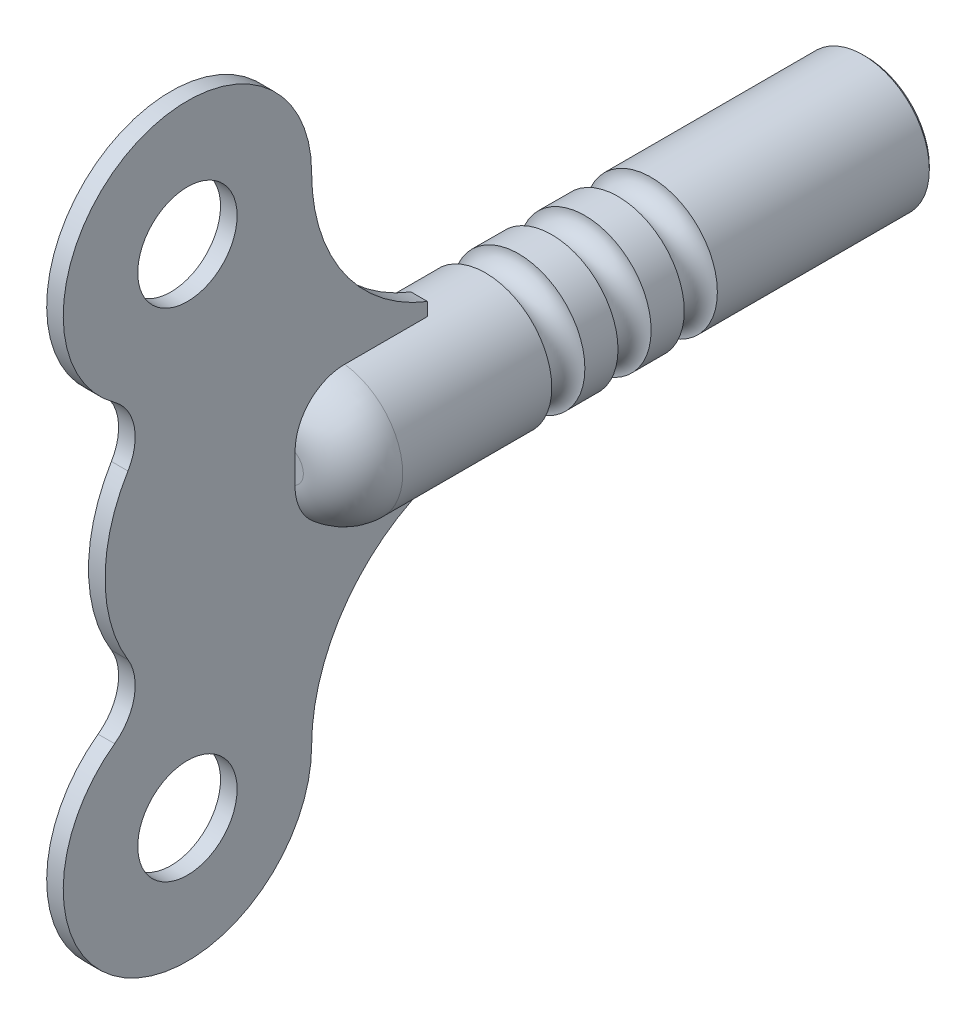
from build123d import *

# Parameters (mm, degrees)
SKETCH1_R           = 4
BOSS_EXTRUDE1_DEPTH = 35
FILLET1_R           = 3
SKETCH3_R           = 3
BOSS_EXTRUDE2_DEPTH = 0.5
FILLET2_R           = 3
SKETCH5_W           = 4.8
SKETCH5_H           = 4.8
CUT_EXTRUDE1_DEPTH  = 12
SKETCH6_R           = 1
CHAMFER1_SIZE       = 0.2


with BuildPart() as part:
    # Sketch1 → Boss-Extrude1 (new body)
    with BuildSketch(Plane.XY):
        with Locations((0, -108.5)):
            Circle(SKETCH1_R)
    extrude(amount=BOSS_EXTRUDE1_DEPTH)

    # Fillet1
    fillet1_edges = [part.edges().sort_by_distance(p)[0] for p in [
        (-4, -108.5, 35),
    ]]
    fillet(fillet1_edges, radius=FILLET1_R)

    # Sketch3 → Boss-Extrude2 (add, symmetric)
    with BuildSketch(Plane(origin=(0, 0, 0), x_dir=(0, 0, -1), z_dir=(1, 0, 0))):
        with BuildLine():
            Line((-46.473188612, -108.5), (-27, -108.5))
            Line((-27, -108.5), (-27, -103.746950766))
            ThreePointArc((-27, -103.746950766), (-32.082951062, -99.704836823), (-34, -93.5))
            ThreePointArc((-34, -93.5), (-46.36763953, -87.794205979), (-42.681622775, -100.90633294))
            ThreePointArc((-42.681622775, -100.90633294), (-45.47260402, -104.256188302), (-46.473188612, -108.5))
        make_face()
        with Locations((-41.5, -93.5)):
            Circle(SKETCH3_R, mode=Mode.SUBTRACT)
    boss_extrude2 = extrude(amount=BOSS_EXTRUDE2_DEPTH, both=True)

    # Mirror1: Boss-Extrude2 across plane
    add(boss_extrude2.mirror(Plane(origin=(0.5, -108.5, 46.473188612), x_dir=(0, 0, 1), z_dir=(0, 1, 0))))

    # Fillet2
    fillet2_edges = [part.edges().sort_by_distance(p)[0] for p in [
        (0, -100.90633294, 42.681622775),
        (0, -116.09366706, 42.681622775),
    ]]
    fillet(fillet2_edges, radius=FILLET2_R)

    # Sketch5 → Cut-Extrude1 (cut)
    with BuildSketch(Plane.XY):
        with Locations((0, -108.5)):
            Rectangle(SKETCH5_W, SKETCH5_H)
    extrude(amount=CUT_EXTRUDE1_DEPTH, mode=Mode.SUBTRACT)

    # Sketch6 → Cut-Revolve1 (revolve, cut)
    with BuildSketch(Plane(origin=(0, 0, 0), x_dir=(0, 0, -1), z_dir=(1, 0, 0))):
        with Locations((-14, -104.5)):
            Circle(SKETCH6_R)
        with Locations((-18, -104.5)):
            Circle(SKETCH6_R)
        with Locations((-22, -104.5)):
            Circle(SKETCH6_R)
    revolve(axis=Axis((0, -108.5, 35), (0, 0, -1)), mode=Mode.SUBTRACT)

    # Chamfer1
    chamfer1_edges = [part.edges().sort_by_distance(p)[0] for p in [
        (-4, -108.5, 0),
        (0, -106.1, 0),
        (-2.4, -108.5, 0),
        (0, -110.9, 0),
        (2.4, -108.5, 0),
    ]]
    chamfer(chamfer1_edges, length=CHAMFER1_SIZE)


solid = part.part
